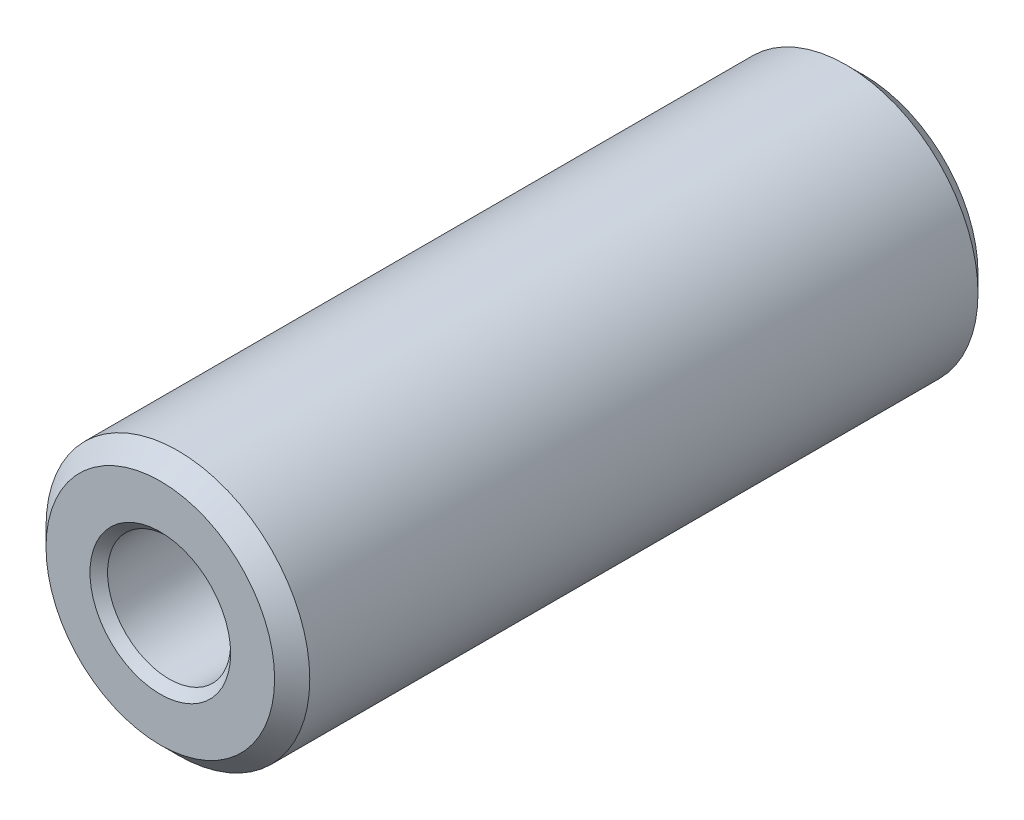
from build123d import *

# Parameters (mm, degrees)
SKETCH_1_R      = 15
SKETCH_1_R_2    = 7
EXTRUDE_1_DEPTH = 80
CHAMFER_1_SIZE  = 1
CHAMFER_2_SIZE  = 2


with BuildPart() as part:
    # Эскиз1 → Бобышка-Вытянуть1 (new body)
    with BuildSketch(Plane.XY):
        Circle(SKETCH_1_R)
        Circle(SKETCH_1_R_2, mode=Mode.SUBTRACT)
    extrude(amount=EXTRUDE_1_DEPTH)

    # Фаска1
    chamfer_1_edges = [part.edges().sort_by_distance(p)[0] for p in [
        (-7, 0, 0),
        (-7, 0, 80),
    ]]
    chamfer(chamfer_1_edges, length=CHAMFER_1_SIZE)

    # Фаска2
    chamfer_2_edges = [part.edges().sort_by_distance(p)[0] for p in [
        (-15, 0, 0),
        (-15, 0, 80),
    ]]
    chamfer(chamfer_2_edges, length=CHAMFER_2_SIZE)


solid = part.part
